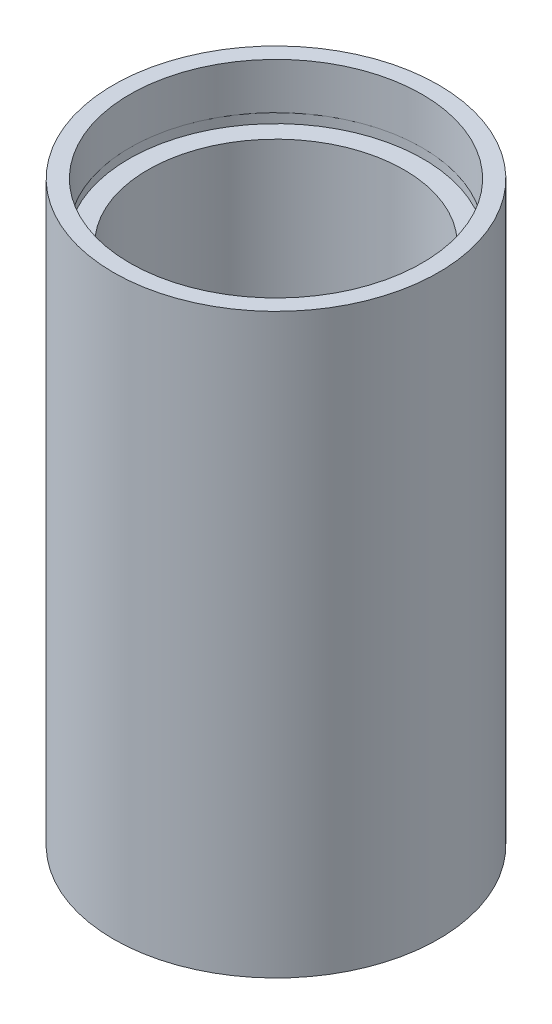
from build123d import *


with BuildPart() as part:
    # 草图1 → 旋转1 (revolve)
    with BuildSketch(Plane.XY, mode=Mode.PRIVATE) as revolve_1_sk:
        Polygon((13.75, 0), (13.75, 4.5), (14.35, 4.5), (14.35, 5.5), (12.5, 5.5), (12.5, 50.8), (14.35, 50.8), (14.35, 51.8), (14.25, 51.8), (14.25, 56.3), (15.85, 56.3), (15.85, 0), align=None)
    revolve(revolve_1_sk.sketch.rotate(Axis((0, 161.376166943, 0), (0, -1, 0)), 90), axis=Axis((0, 161.376166943, 0), (0, -1, 0)))  # turned: the seam where the file's is


solid = part.part
